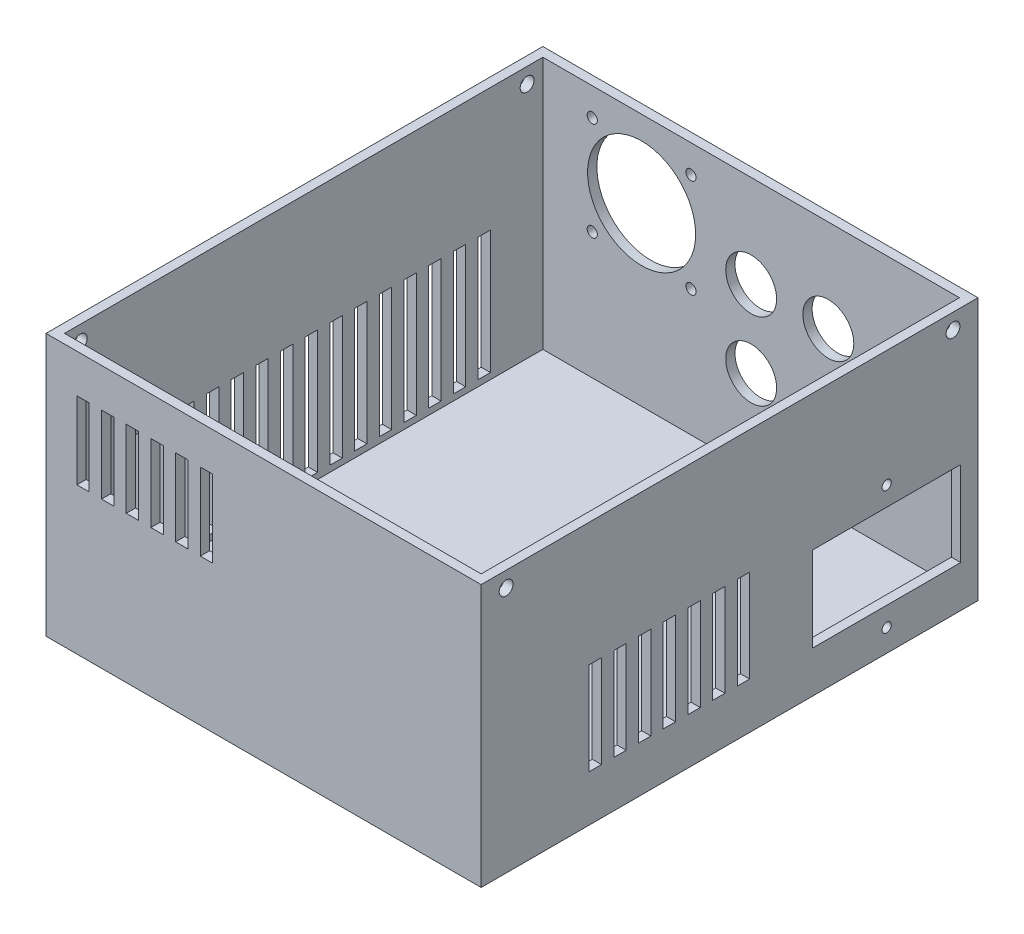
from build123d import *

# Parameters (mm, degrees)
SKETCH1_W                      = 135
SKETCH1_H                      = 155
BOSS_EXTRUDE1_DEPTH            = 3
SKETCH3_W                      = 141
SKETCH3_H                      = 161
SKETCH3_W_2                    = 135
SKETCH3_H_2                    = 155
BOSS_EXTRUDE3_DEPTH            = 85
CUT_EXTRUDE1_REACH             = 143
SKETCH4_W                      = 4
SKETCH4_H                      = 40
CUT_EXTRUDE2_REACH             = 163
SKETCH5_R                      = 17.5
SKETCH5_R_2                    = 1.65
CUT_EXTRUDE3_REACH             = 143
SKETCH6_R                      = 1.5
SKETCH6_W                      = 48
SKETCH6_H                      = 27.5
CUT_EXTRUDE3_DIRECTION_2_DEPTH = 1
CUT_EXTRUDE4_REACH             = 163
SKETCH7_R                      = 8.25
CUT_EXTRUDE5_REACH             = 143
SKETCH8_W                      = 4
SKETCH8_H                      = 30
CUT_EXTRUDE6_REACH             = 163
SKETCH9_W                      = 4
SKETCH9_H                      = 25
SKETCH11_R                     = 2.25
CUT_EXTRUDE7_DEPTH             = 142


with BuildPart() as part:
    # Sketch1 → Boss-Extrude1 (new body)
    with BuildSketch(Plane(origin=(0, 0, 0), x_dir=(1, 0, 0), z_dir=(0, 1, 0))):
        Rectangle(SKETCH1_W, SKETCH1_H)
    extrude(amount=BOSS_EXTRUDE1_DEPTH)

    # Sketch3 → Boss-Extrude3 (add)
    with BuildSketch(Plane(origin=(0, 0, 0), x_dir=(1, 0, 0), z_dir=(0, 1, 0))):
        Rectangle(SKETCH3_W, SKETCH3_H)
        Rectangle(SKETCH3_W_2, SKETCH3_H_2, mode=Mode.SUBTRACT)
    extrude(amount=BOSS_EXTRUDE3_DEPTH)

    # Sketch4 → Cut-Extrude1 (cut, up to next)
    with BuildSketch(Plane.ZY.offset(70.5), mode=Mode.PRIVATE) as cut_extrude1_sk1:
        with Locations((-50.5, 25)):
            Rectangle(SKETCH4_W, SKETCH4_H)
    cut_extrude1_tool1 = extrude(cut_extrude1_sk1.sketch, amount=-CUT_EXTRUDE1_REACH, mode=Mode.PRIVATE) & part.part
    add(cut_extrude1_tool1.solids().sort_by_distance((-70.5, 25, -50.5))[0], mode=Mode.SUBTRACT)
    # Sketch4 → Cut-Extrude1 (cut, up to next)
    with BuildSketch(Plane.ZY.offset(70.5), mode=Mode.PRIVATE) as cut_extrude1_sk2:
        with Locations((-58.5, 25)):
            Rectangle(SKETCH4_W, SKETCH4_H)
    cut_extrude1_tool2 = extrude(cut_extrude1_sk2.sketch, amount=-CUT_EXTRUDE1_REACH, mode=Mode.PRIVATE) & part.part
    add(cut_extrude1_tool2.solids().sort_by_distance((-70.5, 25, -58.5))[0], mode=Mode.SUBTRACT)
    # Sketch4 → Cut-Extrude1 (cut, up to next)
    with BuildSketch(Plane.ZY.offset(70.5), mode=Mode.PRIVATE) as cut_extrude1_sk3:
        with Locations((-42.5, 25)):
            Rectangle(SKETCH4_W, SKETCH4_H)
    cut_extrude1_tool3 = extrude(cut_extrude1_sk3.sketch, amount=-CUT_EXTRUDE1_REACH, mode=Mode.PRIVATE) & part.part
    add(cut_extrude1_tool3.solids().sort_by_distance((-70.5, 25, -42.5))[0], mode=Mode.SUBTRACT)
    # Sketch4 → Cut-Extrude1 (cut, up to next)
    with BuildSketch(Plane.ZY.offset(70.5), mode=Mode.PRIVATE) as cut_extrude1_sk4:
        with Locations((-34.5, 25)):
            Rectangle(SKETCH4_W, SKETCH4_H)
    cut_extrude1_tool4 = extrude(cut_extrude1_sk4.sketch, amount=-CUT_EXTRUDE1_REACH, mode=Mode.PRIVATE) & part.part
    add(cut_extrude1_tool4.solids().sort_by_distance((-70.5, 25, -34.5))[0], mode=Mode.SUBTRACT)
    # Sketch4 → Cut-Extrude1 (cut, up to next)
    with BuildSketch(Plane.ZY.offset(70.5), mode=Mode.PRIVATE) as cut_extrude1_sk5:
        with Locations((-26.5, 25)):
            Rectangle(SKETCH4_W, SKETCH4_H)
    cut_extrude1_tool5 = extrude(cut_extrude1_sk5.sketch, amount=-CUT_EXTRUDE1_REACH, mode=Mode.PRIVATE) & part.part
    add(cut_extrude1_tool5.solids().sort_by_distance((-70.5, 25, -26.5))[0], mode=Mode.SUBTRACT)
    # Sketch4 → Cut-Extrude1 (cut, up to next)
    with BuildSketch(Plane.ZY.offset(70.5), mode=Mode.PRIVATE) as cut_extrude1_sk6:
        with Locations((-18.5, 25)):
            Rectangle(SKETCH4_W, SKETCH4_H)
    cut_extrude1_tool6 = extrude(cut_extrude1_sk6.sketch, amount=-CUT_EXTRUDE1_REACH, mode=Mode.PRIVATE) & part.part
    add(cut_extrude1_tool6.solids().sort_by_distance((-70.5, 25, -18.5))[0], mode=Mode.SUBTRACT)
    # Sketch4 → Cut-Extrude1 (cut, up to next)
    with BuildSketch(Plane.ZY.offset(70.5), mode=Mode.PRIVATE) as cut_extrude1_sk7:
        with Locations((-10.5, 25)):
            Rectangle(SKETCH4_W, SKETCH4_H)
    cut_extrude1_tool7 = extrude(cut_extrude1_sk7.sketch, amount=-CUT_EXTRUDE1_REACH, mode=Mode.PRIVATE) & part.part
    add(cut_extrude1_tool7.solids().sort_by_distance((-70.5, 25, -10.5))[0], mode=Mode.SUBTRACT)
    # Sketch4 → Cut-Extrude1 (cut, up to next)
    with BuildSketch(Plane.ZY.offset(70.5), mode=Mode.PRIVATE) as cut_extrude1_sk8:
        with Locations((-2.5, 25)):
            Rectangle(SKETCH4_W, SKETCH4_H)
    cut_extrude1_tool8 = extrude(cut_extrude1_sk8.sketch, amount=-CUT_EXTRUDE1_REACH, mode=Mode.PRIVATE) & part.part
    add(cut_extrude1_tool8.solids().sort_by_distance((-70.5, 25, -2.5))[0], mode=Mode.SUBTRACT)
    # Sketch4 → Cut-Extrude1 (cut, up to next)
    with BuildSketch(Plane.ZY.offset(70.5), mode=Mode.PRIVATE) as cut_extrude1_sk9:
        with Locations((5.5, 25)):
            Rectangle(SKETCH4_W, SKETCH4_H)
    cut_extrude1_tool9 = extrude(cut_extrude1_sk9.sketch, amount=-CUT_EXTRUDE1_REACH, mode=Mode.PRIVATE) & part.part
    add(cut_extrude1_tool9.solids().sort_by_distance((-70.5, 25, 5.5))[0], mode=Mode.SUBTRACT)
    # Sketch4 → Cut-Extrude1 (cut, up to next)
    with BuildSketch(Plane.ZY.offset(70.5), mode=Mode.PRIVATE) as cut_extrude1_sk10:
        with Locations((13.5, 25)):
            Rectangle(SKETCH4_W, SKETCH4_H)
    cut_extrude1_tool10 = extrude(cut_extrude1_sk10.sketch, amount=-CUT_EXTRUDE1_REACH, mode=Mode.PRIVATE) & part.part
    add(cut_extrude1_tool10.solids().sort_by_distance((-70.5, 25, 13.5))[0], mode=Mode.SUBTRACT)
    # Sketch4 → Cut-Extrude1 (cut, up to next)
    with BuildSketch(Plane.ZY.offset(70.5), mode=Mode.PRIVATE) as cut_extrude1_sk11:
        with Locations((21.5, 25)):
            Rectangle(SKETCH4_W, SKETCH4_H)
    cut_extrude1_tool11 = extrude(cut_extrude1_sk11.sketch, amount=-CUT_EXTRUDE1_REACH, mode=Mode.PRIVATE) & part.part
    add(cut_extrude1_tool11.solids().sort_by_distance((-70.5, 25, 21.5))[0], mode=Mode.SUBTRACT)
    # Sketch4 → Cut-Extrude1 (cut, up to next)
    with BuildSketch(Plane.ZY.offset(70.5), mode=Mode.PRIVATE) as cut_extrude1_sk12:
        with Locations((29.5, 25)):
            Rectangle(SKETCH4_W, SKETCH4_H)
    cut_extrude1_tool12 = extrude(cut_extrude1_sk12.sketch, amount=-CUT_EXTRUDE1_REACH, mode=Mode.PRIVATE) & part.part
    add(cut_extrude1_tool12.solids().sort_by_distance((-70.5, 25, 29.5))[0], mode=Mode.SUBTRACT)
    # Sketch4 → Cut-Extrude1 (cut, up to next)
    with BuildSketch(Plane.ZY.offset(70.5), mode=Mode.PRIVATE) as cut_extrude1_sk13:
        with Locations((37.5, 25)):
            Rectangle(SKETCH4_W, SKETCH4_H)
    cut_extrude1_tool13 = extrude(cut_extrude1_sk13.sketch, amount=-CUT_EXTRUDE1_REACH, mode=Mode.PRIVATE) & part.part
    add(cut_extrude1_tool13.solids().sort_by_distance((-70.5, 25, 37.5))[0], mode=Mode.SUBTRACT)
    # Sketch4 → Cut-Extrude1 (cut, up to next)
    with BuildSketch(Plane.ZY.offset(70.5), mode=Mode.PRIVATE) as cut_extrude1_sk14:
        with Locations((45.5, 25)):
            Rectangle(SKETCH4_W, SKETCH4_H)
    cut_extrude1_tool14 = extrude(cut_extrude1_sk14.sketch, amount=-CUT_EXTRUDE1_REACH, mode=Mode.PRIVATE) & part.part
    add(cut_extrude1_tool14.solids().sort_by_distance((-70.5, 25, 45.5))[0], mode=Mode.SUBTRACT)
    # Sketch4 → Cut-Extrude1 (cut, up to next)
    with BuildSketch(Plane.ZY.offset(70.5), mode=Mode.PRIVATE) as cut_extrude1_sk15:
        with Locations((53.5, 25)):
            Rectangle(SKETCH4_W, SKETCH4_H)
    cut_extrude1_tool15 = extrude(cut_extrude1_sk15.sketch, amount=-CUT_EXTRUDE1_REACH, mode=Mode.PRIVATE) & part.part
    add(cut_extrude1_tool15.solids().sort_by_distance((-70.5, 25, 53.5))[0], mode=Mode.SUBTRACT)

    # Sketch5 → Cut-Extrude2 (cut, up to next)
    with BuildSketch(Plane.XY.offset(-80.5), mode=Mode.PRIVATE) as cut_extrude2_sk1:
        with Locations((-35.5, 60)):
            Circle(SKETCH5_R)
    cut_extrude2_tool1 = extrude(cut_extrude2_sk1.sketch, amount=CUT_EXTRUDE2_REACH, mode=Mode.PRIVATE) & part.part
    add(cut_extrude2_tool1.solids().sort_by_distance((-35.5, 60, -80.5))[0], mode=Mode.SUBTRACT)
    # Sketch5 → Cut-Extrude2 (cut, up to next)
    with BuildSketch(Plane.XY.offset(-80.5), mode=Mode.PRIVATE) as cut_extrude2_sk2:
        with Locations((-51.5, 44)):
            Circle(SKETCH5_R_2)
    cut_extrude2_tool2 = extrude(cut_extrude2_sk2.sketch, amount=CUT_EXTRUDE2_REACH, mode=Mode.PRIVATE) & part.part
    add(cut_extrude2_tool2.solids().sort_by_distance((-51.5, 44, -80.5))[0], mode=Mode.SUBTRACT)
    # Sketch5 → Cut-Extrude2 (cut, up to next)
    with BuildSketch(Plane.XY.offset(-80.5), mode=Mode.PRIVATE) as cut_extrude2_sk3:
        with Locations((-19.5, 44)):
            Circle(SKETCH5_R_2)
    cut_extrude2_tool3 = extrude(cut_extrude2_sk3.sketch, amount=CUT_EXTRUDE2_REACH, mode=Mode.PRIVATE) & part.part
    add(cut_extrude2_tool3.solids().sort_by_distance((-19.5, 44, -80.5))[0], mode=Mode.SUBTRACT)
    # Sketch5 → Cut-Extrude2 (cut, up to next)
    with BuildSketch(Plane.XY.offset(-80.5), mode=Mode.PRIVATE) as cut_extrude2_sk4:
        with Locations((-19.5, 76)):
            Circle(SKETCH5_R_2)
    cut_extrude2_tool4 = extrude(cut_extrude2_sk4.sketch, amount=CUT_EXTRUDE2_REACH, mode=Mode.PRIVATE) & part.part
    add(cut_extrude2_tool4.solids().sort_by_distance((-19.5, 76, -80.5))[0], mode=Mode.SUBTRACT)
    # Sketch5 → Cut-Extrude2 (cut, up to next)
    with BuildSketch(Plane.XY.offset(-80.5), mode=Mode.PRIVATE) as cut_extrude2_sk5:
        with Locations((-51.5, 76)):
            Circle(SKETCH5_R_2)
    cut_extrude2_tool5 = extrude(cut_extrude2_sk5.sketch, amount=CUT_EXTRUDE2_REACH, mode=Mode.PRIVATE) & part.part
    add(cut_extrude2_tool5.solids().sort_by_distance((-51.5, 76, -80.5))[0], mode=Mode.SUBTRACT)

    # Sketch6 → Cut-Extrude3 (cut, up to next)
    with BuildSketch(Plane(origin=(70.5, 0, 0), x_dir=(0, 0, -1), z_dir=(1, 0, 0)), mode=Mode.PRIVATE) as cut_extrude3_sk1:
        with Locations((50.9, 47.25)):
            Circle(SKETCH6_R)
    cut_extrude3_tool1 = extrude(cut_extrude3_sk1.sketch, amount=-CUT_EXTRUDE3_REACH, mode=Mode.PRIVATE) & part.part
    add(cut_extrude3_tool1.solids().sort_by_distance((70.5, 47.25, -50.9))[0], mode=Mode.SUBTRACT)
    # Sketch6 → Cut-Extrude3 (cut, up to next)
    with BuildSketch(Plane(origin=(70.5, 0, 0), x_dir=(0, 0, -1), z_dir=(1, 0, 0)), mode=Mode.PRIVATE) as cut_extrude3_sk2:
        with Locations((50.9, 7.25)):
            Circle(SKETCH6_R)
    cut_extrude3_tool2 = extrude(cut_extrude3_sk2.sketch, amount=-CUT_EXTRUDE3_REACH, mode=Mode.PRIVATE) & part.part
    add(cut_extrude3_tool2.solids().sort_by_distance((70.5, 7.25, -50.9))[0], mode=Mode.SUBTRACT)
    # Sketch6 → Cut-Extrude3 (cut, up to next)
    with BuildSketch(Plane(origin=(70.5, 0, 0), x_dir=(0, 0, -1), z_dir=(1, 0, 0)), mode=Mode.PRIVATE) as cut_extrude3_sk3:
        with Locations((50.9, 27.25)):
            Rectangle(SKETCH6_W, SKETCH6_H)
    cut_extrude3_tool3 = extrude(cut_extrude3_sk3.sketch, amount=-CUT_EXTRUDE3_REACH, mode=Mode.PRIVATE) & part.part
    add(cut_extrude3_tool3.solids().sort_by_distance((70.5, 27.25, -50.9))[0], mode=Mode.SUBTRACT)

    # Sketch6 → Cut-Extrude3 direction 2 (cut)
    with BuildSketch(Plane(origin=(70.5, 0, 0), x_dir=(0, 0, -1), z_dir=(1, 0, 0))):
        with Locations((50.9, 47.25)):
            Circle(SKETCH6_R)
        with Locations((50.9, 7.25)):
            Circle(SKETCH6_R)
        with Locations((50.9, 27.25)):
            Rectangle(SKETCH6_W, SKETCH6_H)
    extrude(amount=CUT_EXTRUDE3_DIRECTION_2_DEPTH, mode=Mode.SUBTRACT)

    # Sketch7 → Cut-Extrude4 (cut, up to next)
    with BuildSketch(Plane(origin=(0, 0, -80.5), x_dir=(-1, 0, 0), z_dir=(0, 0, -1)), mode=Mode.PRIVATE) as cut_extrude4_sk1:
        with Locations((0, 55)):
            Circle(SKETCH7_R)
    cut_extrude4_tool1 = extrude(cut_extrude4_sk1.sketch, amount=-CUT_EXTRUDE4_REACH, mode=Mode.PRIVATE) & part.part
    add(cut_extrude4_tool1.solids().sort_by_distance((0, 55, -80.5))[0], mode=Mode.SUBTRACT)
    # Sketch7 → Cut-Extrude4 (cut, up to next)
    with BuildSketch(Plane(origin=(0, 0, -80.5), x_dir=(-1, 0, 0), z_dir=(0, 0, -1)), mode=Mode.PRIVATE) as cut_extrude4_sk2:
        with Locations((-25, 55)):
            Circle(SKETCH7_R)
    cut_extrude4_tool2 = extrude(cut_extrude4_sk2.sketch, amount=-CUT_EXTRUDE4_REACH, mode=Mode.PRIVATE) & part.part
    add(cut_extrude4_tool2.solids().sort_by_distance((25, 55, -80.5))[0], mode=Mode.SUBTRACT)
    # Sketch7 → Cut-Extrude4 (cut, up to next)
    with BuildSketch(Plane(origin=(0, 0, -80.5), x_dir=(-1, 0, 0), z_dir=(0, 0, -1)), mode=Mode.PRIVATE) as cut_extrude4_sk3:
        with Locations((0, 30)):
            Circle(SKETCH7_R)
    cut_extrude4_tool3 = extrude(cut_extrude4_sk3.sketch, amount=-CUT_EXTRUDE4_REACH, mode=Mode.PRIVATE) & part.part
    add(cut_extrude4_tool3.solids().sort_by_distance((0, 30, -80.5))[0], mode=Mode.SUBTRACT)
    # Sketch7 → Cut-Extrude4 (cut, up to next)
    with BuildSketch(Plane(origin=(0, 0, -80.5), x_dir=(-1, 0, 0), z_dir=(0, 0, -1)), mode=Mode.PRIVATE) as cut_extrude4_sk4:
        with Locations((-25, 30)):
            Circle(SKETCH7_R)
    cut_extrude4_tool4 = extrude(cut_extrude4_sk4.sketch, amount=-CUT_EXTRUDE4_REACH, mode=Mode.PRIVATE) & part.part
    add(cut_extrude4_tool4.solids().sort_by_distance((25, 30, -80.5))[0], mode=Mode.SUBTRACT)

    # Sketch8 → Cut-Extrude5 (cut, up to next)
    with BuildSketch(Plane(origin=(70.5, 0, 0), x_dir=(0, 0, -1), z_dir=(1, 0, 0)), mode=Mode.PRIVATE) as cut_extrude5_sk1:
        with Locations((-35.5, 30)):
            Rectangle(SKETCH8_W, SKETCH8_H)
    cut_extrude5_tool1 = extrude(cut_extrude5_sk1.sketch, amount=-CUT_EXTRUDE5_REACH, mode=Mode.PRIVATE) & part.part
    add(cut_extrude5_tool1.solids().sort_by_distance((70.5, 30, 35.5))[0], mode=Mode.SUBTRACT)
    # Sketch8 → Cut-Extrude5 (cut, up to next)
    with BuildSketch(Plane(origin=(70.5, 0, 0), x_dir=(0, 0, -1), z_dir=(1, 0, 0)), mode=Mode.PRIVATE) as cut_extrude5_sk2:
        with Locations((-43.5, 30)):
            Rectangle(SKETCH8_W, SKETCH8_H)
    cut_extrude5_tool2 = extrude(cut_extrude5_sk2.sketch, amount=-CUT_EXTRUDE5_REACH, mode=Mode.PRIVATE) & part.part
    add(cut_extrude5_tool2.solids().sort_by_distance((70.5, 30, 43.5))[0], mode=Mode.SUBTRACT)
    # Sketch8 → Cut-Extrude5 (cut, up to next)
    with BuildSketch(Plane(origin=(70.5, 0, 0), x_dir=(0, 0, -1), z_dir=(1, 0, 0)), mode=Mode.PRIVATE) as cut_extrude5_sk3:
        with Locations((-27.5, 30)):
            Rectangle(SKETCH8_W, SKETCH8_H)
    cut_extrude5_tool3 = extrude(cut_extrude5_sk3.sketch, amount=-CUT_EXTRUDE5_REACH, mode=Mode.PRIVATE) & part.part
    add(cut_extrude5_tool3.solids().sort_by_distance((70.5, 30, 27.5))[0], mode=Mode.SUBTRACT)
    # Sketch8 → Cut-Extrude5 (cut, up to next)
    with BuildSketch(Plane(origin=(70.5, 0, 0), x_dir=(0, 0, -1), z_dir=(1, 0, 0)), mode=Mode.PRIVATE) as cut_extrude5_sk4:
        with Locations((-19.5, 30)):
            Rectangle(SKETCH8_W, SKETCH8_H)
    cut_extrude5_tool4 = extrude(cut_extrude5_sk4.sketch, amount=-CUT_EXTRUDE5_REACH, mode=Mode.PRIVATE) & part.part
    add(cut_extrude5_tool4.solids().sort_by_distance((70.5, 30, 19.5))[0], mode=Mode.SUBTRACT)
    # Sketch8 → Cut-Extrude5 (cut, up to next)
    with BuildSketch(Plane(origin=(70.5, 0, 0), x_dir=(0, 0, -1), z_dir=(1, 0, 0)), mode=Mode.PRIVATE) as cut_extrude5_sk5:
        with Locations((-11.5, 30)):
            Rectangle(SKETCH8_W, SKETCH8_H)
    cut_extrude5_tool5 = extrude(cut_extrude5_sk5.sketch, amount=-CUT_EXTRUDE5_REACH, mode=Mode.PRIVATE) & part.part
    add(cut_extrude5_tool5.solids().sort_by_distance((70.5, 30, 11.5))[0], mode=Mode.SUBTRACT)
    # Sketch8 → Cut-Extrude5 (cut, up to next)
    with BuildSketch(Plane(origin=(70.5, 0, 0), x_dir=(0, 0, -1), z_dir=(1, 0, 0)), mode=Mode.PRIVATE) as cut_extrude5_sk6:
        with Locations((-3.5, 30)):
            Rectangle(SKETCH8_W, SKETCH8_H)
    cut_extrude5_tool6 = extrude(cut_extrude5_sk6.sketch, amount=-CUT_EXTRUDE5_REACH, mode=Mode.PRIVATE) & part.part
    add(cut_extrude5_tool6.solids().sort_by_distance((70.5, 30, 3.5))[0], mode=Mode.SUBTRACT)
    # Sketch8 → Cut-Extrude5 (cut, up to next)
    with BuildSketch(Plane(origin=(70.5, 0, 0), x_dir=(0, 0, -1), z_dir=(1, 0, 0)), mode=Mode.PRIVATE) as cut_extrude5_sk7:
        with Locations((4.5, 30)):
            Rectangle(SKETCH8_W, SKETCH8_H)
    cut_extrude5_tool7 = extrude(cut_extrude5_sk7.sketch, amount=-CUT_EXTRUDE5_REACH, mode=Mode.PRIVATE) & part.part
    add(cut_extrude5_tool7.solids().sort_by_distance((70.5, 30, -4.5))[0], mode=Mode.SUBTRACT)

    # Sketch9 → Cut-Extrude6 (cut, up to next)
    with BuildSketch(Plane.XY.offset(80.5), mode=Mode.PRIVATE) as cut_extrude6_sk1:
        with Locations((-50.5, 60)):
            Rectangle(SKETCH9_W, SKETCH9_H)
    cut_extrude6_tool1 = extrude(cut_extrude6_sk1.sketch, amount=-CUT_EXTRUDE6_REACH, mode=Mode.PRIVATE) & part.part
    add(cut_extrude6_tool1.solids().sort_by_distance((-50.5, 60, 80.5))[0], mode=Mode.SUBTRACT)
    # Sketch9 → Cut-Extrude6 (cut, up to next)
    with BuildSketch(Plane.XY.offset(80.5), mode=Mode.PRIVATE) as cut_extrude6_sk2:
        with Locations((-58.5, 60)):
            Rectangle(SKETCH9_W, SKETCH9_H)
    cut_extrude6_tool2 = extrude(cut_extrude6_sk2.sketch, amount=-CUT_EXTRUDE6_REACH, mode=Mode.PRIVATE) & part.part
    add(cut_extrude6_tool2.solids().sort_by_distance((-58.5, 60, 80.5))[0], mode=Mode.SUBTRACT)
    # Sketch9 → Cut-Extrude6 (cut, up to next)
    with BuildSketch(Plane.XY.offset(80.5), mode=Mode.PRIVATE) as cut_extrude6_sk3:
        with Locations((-42.5, 60)):
            Rectangle(SKETCH9_W, SKETCH9_H)
    cut_extrude6_tool3 = extrude(cut_extrude6_sk3.sketch, amount=-CUT_EXTRUDE6_REACH, mode=Mode.PRIVATE) & part.part
    add(cut_extrude6_tool3.solids().sort_by_distance((-42.5, 60, 80.5))[0], mode=Mode.SUBTRACT)
    # Sketch9 → Cut-Extrude6 (cut, up to next)
    with BuildSketch(Plane.XY.offset(80.5), mode=Mode.PRIVATE) as cut_extrude6_sk4:
        with Locations((-34.5, 60)):
            Rectangle(SKETCH9_W, SKETCH9_H)
    cut_extrude6_tool4 = extrude(cut_extrude6_sk4.sketch, amount=-CUT_EXTRUDE6_REACH, mode=Mode.PRIVATE) & part.part
    add(cut_extrude6_tool4.solids().sort_by_distance((-34.5, 60, 80.5))[0], mode=Mode.SUBTRACT)
    # Sketch9 → Cut-Extrude6 (cut, up to next)
    with BuildSketch(Plane.XY.offset(80.5), mode=Mode.PRIVATE) as cut_extrude6_sk5:
        with Locations((-26.5, 60)):
            Rectangle(SKETCH9_W, SKETCH9_H)
    cut_extrude6_tool5 = extrude(cut_extrude6_sk5.sketch, amount=-CUT_EXTRUDE6_REACH, mode=Mode.PRIVATE) & part.part
    add(cut_extrude6_tool5.solids().sort_by_distance((-26.5, 60, 80.5))[0], mode=Mode.SUBTRACT)
    # Sketch9 → Cut-Extrude6 (cut, up to next)
    with BuildSketch(Plane.XY.offset(80.5), mode=Mode.PRIVATE) as cut_extrude6_sk6:
        with Locations((-18.5, 60)):
            Rectangle(SKETCH9_W, SKETCH9_H)
    cut_extrude6_tool6 = extrude(cut_extrude6_sk6.sketch, amount=-CUT_EXTRUDE6_REACH, mode=Mode.PRIVATE) & part.part
    add(cut_extrude6_tool6.solids().sort_by_distance((-18.5, 60, 80.5))[0], mode=Mode.SUBTRACT)

    # Sketch11 → Cut-Extrude7 (cut, through all)
    with BuildSketch(Plane.ZY.offset(70.5)):
        with Locations((-72.4, 80)):
            Circle(SKETCH11_R)
        with Locations((72.4, 80)):
            Circle(SKETCH11_R)
    extrude(amount=-CUT_EXTRUDE7_DEPTH, mode=Mode.SUBTRACT)


solid = part.part
